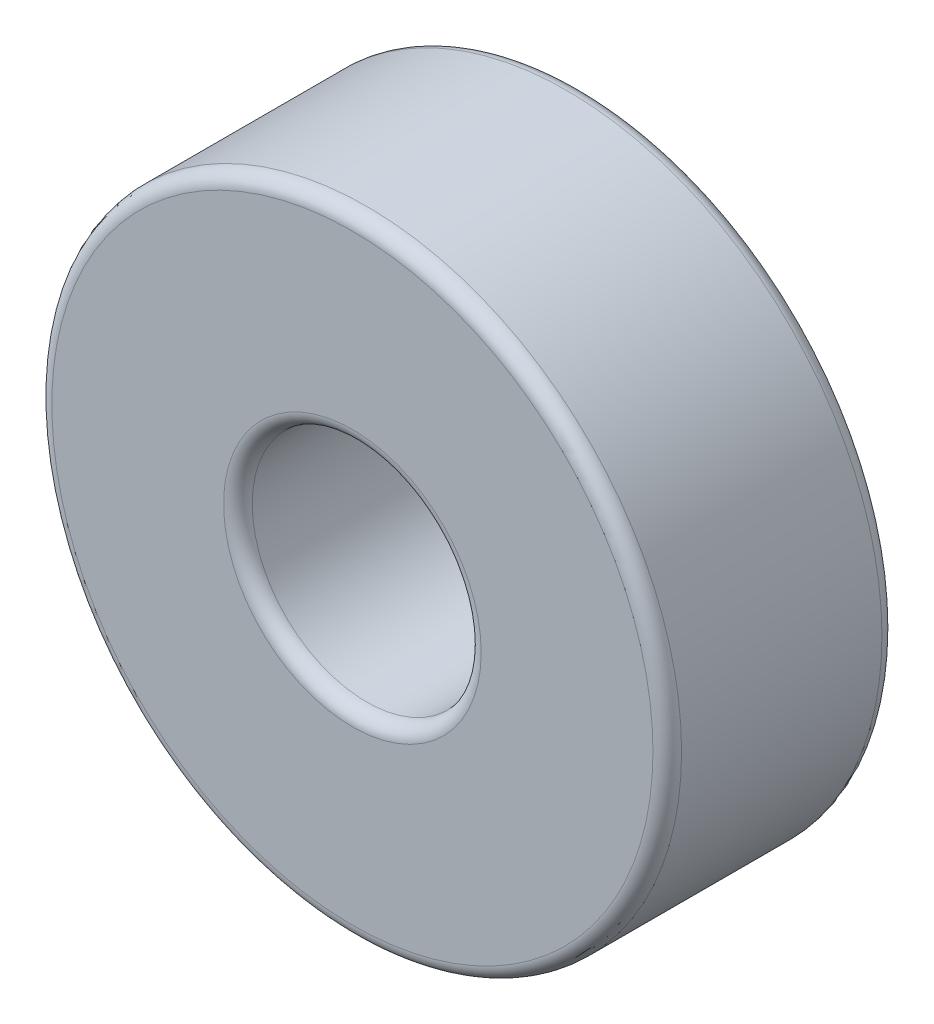
from build123d import *

# Parameters (mm, degrees)
ESQUISSE1_R      = 11
ESQUISSE1_R_2    = 4
EXTRUSION1_DEPTH = 8
CONG_1_R         = 0.5


with BuildPart() as part:
    # Esquisse1 → Extrusion1 (new body)
    with BuildSketch(Plane.XY):
        Circle(ESQUISSE1_R)
        Circle(ESQUISSE1_R_2, mode=Mode.SUBTRACT)
    extrude(amount=EXTRUSION1_DEPTH)

    # Congé1
    cong_1_edges = [part.edges().sort_by_distance(p)[0] for p in [
        (-11, 0, 0),
        (-11, 0, 8),
        (-4, 0, 0),
        (-4, 0, 8),
    ]]
    fillet(cong_1_edges, radius=CONG_1_R)


solid = part.part
